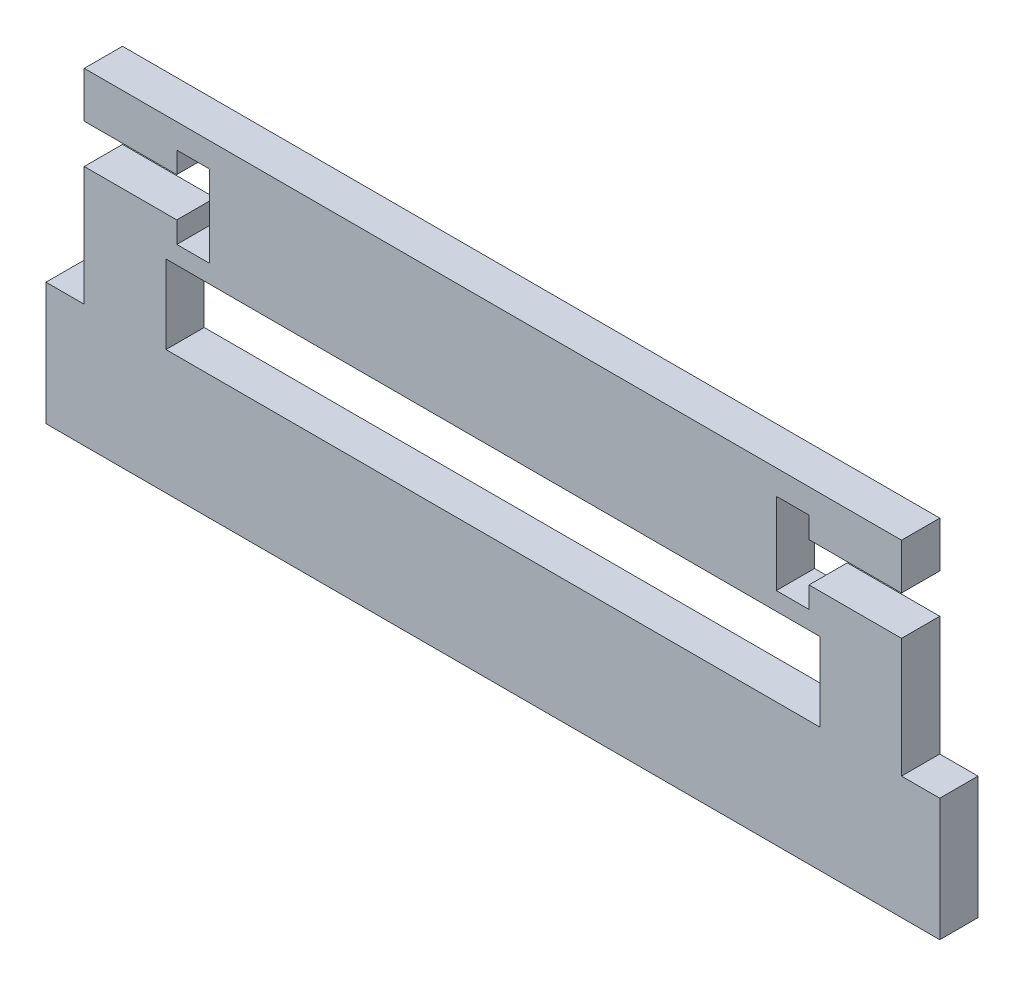
from build123d import *

# Parameters (mm, degrees)
SKETCH1_W           = 63.5
SKETCH1_H           = 25.4
SKETCH1_W_2         = 2.9718
SKETCH1_H_2         = 9.525
BOSS_EXTRUDE1_DEPTH = 2.9718
SKETCH2_W           = 50.8
SKETCH2_H           = 6.096
CUT_EXTRUDE1_DEPTH  = 3.9718
CUT_EXTRUDE2_DEPTH  = 3.9718


with BuildPart() as part:
    # Sketch1 → Boss-Extrude1 (new body)
    with BuildSketch(Plane.XY):
        Rectangle(SKETCH1_W, SKETCH1_H)
        with Locations((-33.2359, -7.9375)):
            Rectangle(SKETCH1_W_2, SKETCH1_H_2)
        with Locations((33.2359, -7.9375)):
            Rectangle(SKETCH1_W_2, SKETCH1_H_2)
    extrude(amount=BOSS_EXTRUDE1_DEPTH)

    # Sketch2 → Cut-Extrude1 (cut, through all)
    with BuildSketch(Plane.XY.offset(2.9718)):
        Rectangle(SKETCH2_W, SKETCH2_H)
    extrude(amount=-CUT_EXTRUDE1_DEPTH, mode=Mode.SUBTRACT)

    # Sketch3 → Cut-Extrude2 (cut, through all)
    with BuildSketch(Plane(origin=(0, 0, 0), x_dir=(-1, 0, 0), z_dir=(0, 0, -1))):
        Polygon((22.0218, 10.795), (22.0218, 4.445), (24.5618, 4.445), (24.5618, 6.096), (31.75, 6.096), (31.75, 9.144), (24.5618, 9.144), (24.5618, 10.795), align=None)
        Polygon((-31.75, 9.144), (-31.75, 6.096), (-24.5618, 6.096), (-24.5618, 4.445), (-22.0218, 4.445), (-22.0218, 10.795), (-24.5618, 10.795), (-24.5618, 9.144), align=None)
    extrude(amount=-CUT_EXTRUDE2_DEPTH, mode=Mode.SUBTRACT)


solid = part.part
